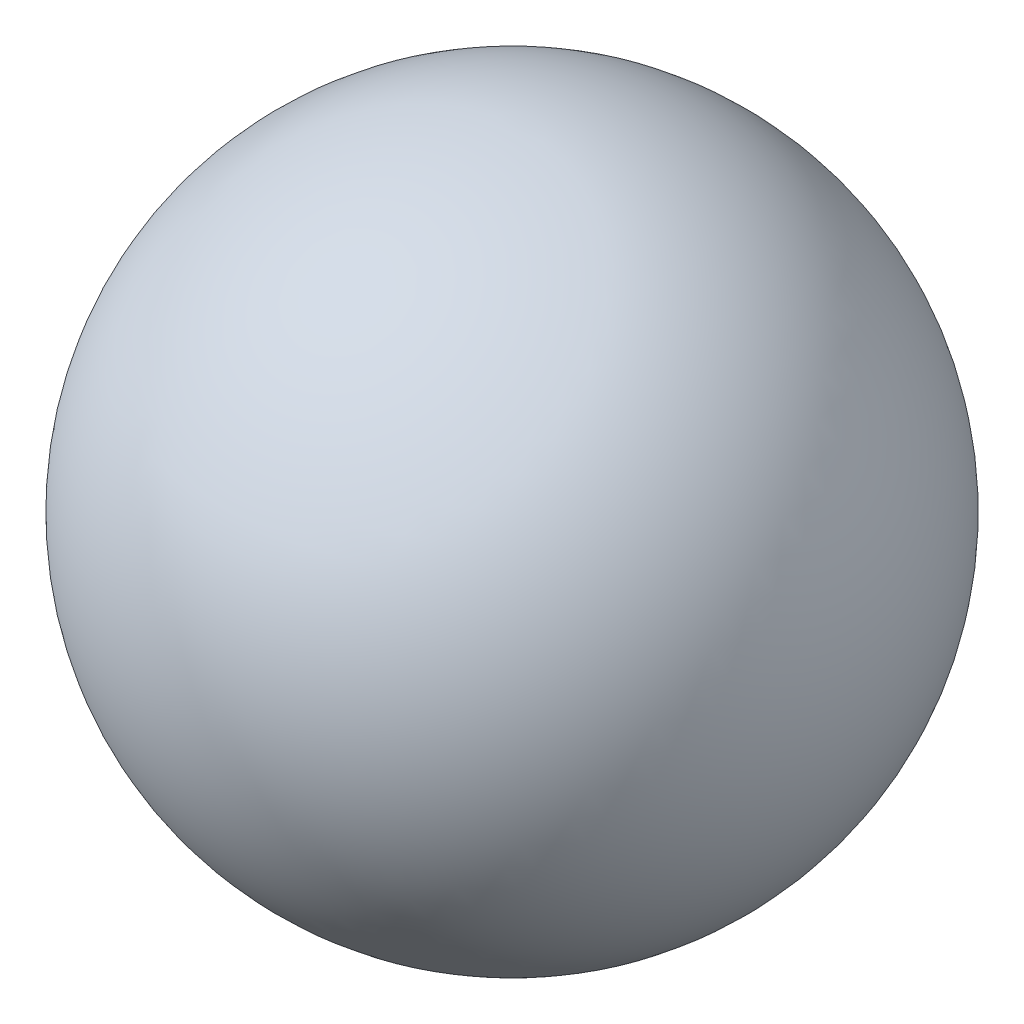
from build123d import *


with BuildPart() as part:
    # Çizim1 → Döndür1 (revolve)
    with BuildSketch(Plane.XY):
        with BuildLine():
            Line((0, 30), (0, -30))
            ThreePointArc((0, -30), (30, 0), (0, 30))
        make_face()
    revolve(axis=Axis((0, 30, 0), (0, -1, 0)))


solid = part.part
